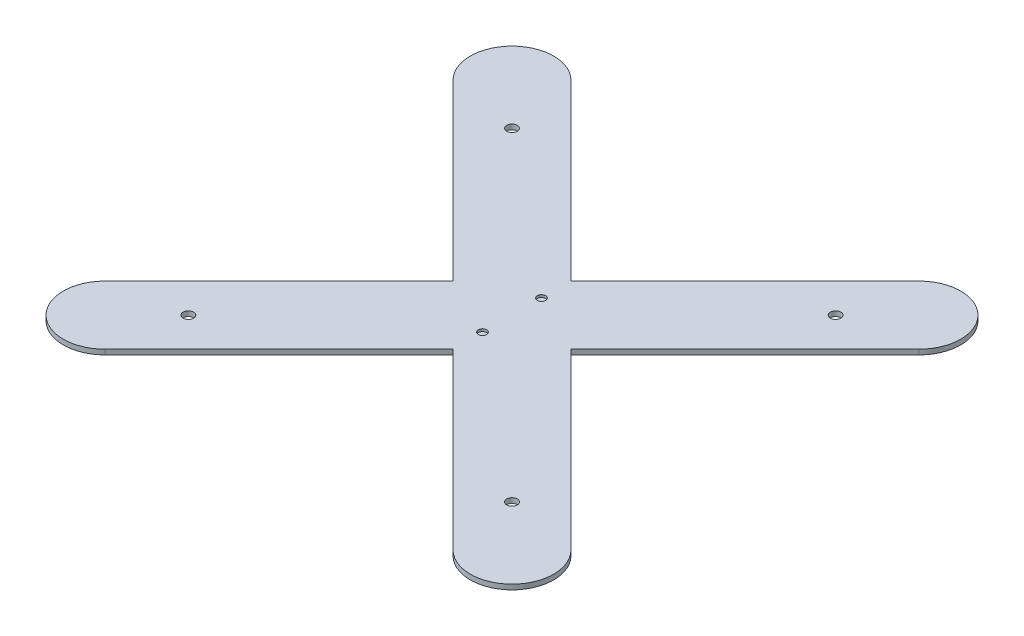
from build123d import *

# Parameters (mm, degrees)
SKETCH2_R           = 3.15
BOSS_EXTRUDE2_DEPTH = 3
SKETCH4_R           = 2.5
CUT_EXTRUDE1_DEPTH  = 1.5


with BuildPart() as part:
    # Sketch2 → Boss-Extrude2 (new body)
    with BuildSketch(Plane(origin=(0, 0, 0), x_dir=(1, 0, 0), z_dir=(0, 1, 0))):
        with BuildLine():
            Line((104.32233047, -139.67766953), (0, -35.355339059))
            Line((0, -35.355339059), (-104.32233047, -139.67766953))
            ThreePointArc((-104.32233047, -139.67766953), (-139.67766953, -139.67766953), (-139.67766953, -104.32233047))
            Line((-139.67766953, -104.32233047), (-35.355339059, 0))
            Line((-35.355339059, 0), (-139.67766953, 104.32233047))
            ThreePointArc((-139.67766953, 104.32233047), (-139.67766953, 139.67766953), (-104.32233047, 139.67766953))
            Line((-104.32233047, 139.67766953), (0, 35.355339059))
            Line((0, 35.355339059), (104.32233047, 139.67766953))
            ThreePointArc((104.32233047, 139.67766953), (139.67766953, 139.67766953), (139.67766953, 104.32233047))
            Line((139.67766953, 104.32233047), (35.355339059, 0))
            Line((35.355339059, 0), (139.67766953, -104.32233047))
            ThreePointArc((139.67766953, -104.32233047), (139.67766953, -139.67766953), (104.32233047, -139.67766953))
        make_face()
        with Locations((-97, 97)):
            Circle(SKETCH2_R, mode=Mode.SUBTRACT)
        with Locations((97, -97)):
            Circle(SKETCH2_R, mode=Mode.SUBTRACT)
        with Locations((97, 97)):
            Circle(SKETCH2_R, mode=Mode.SUBTRACT)
        with Locations((-97, -97)):
            Circle(SKETCH2_R, mode=Mode.SUBTRACT)
    extrude(amount=BOSS_EXTRUDE2_DEPTH)

    # Sketch4 → Cut-Extrude1 (cut)
    with BuildSketch(Plane(origin=(0, 3, 0), x_dir=(1, 0, 0), z_dir=(0, 1, 0))):
        with Locations((0, 17.67766953)):
            Circle(SKETCH4_R)
        with Locations((0, -17.67766953)):
            Circle(SKETCH4_R)
    extrude(amount=-CUT_EXTRUDE1_DEPTH, mode=Mode.SUBTRACT)


solid = part.part
